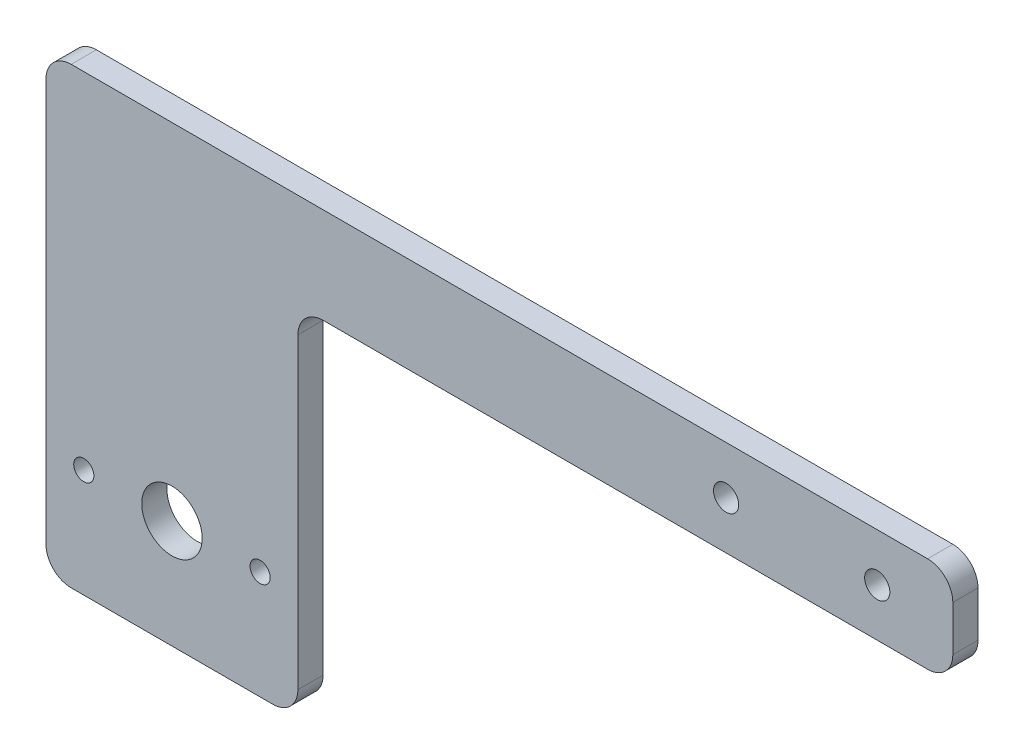
from build123d import *

# Parameters (mm, degrees)
SKETCH1_R           = 2.5
SKETCH1_R_2         = 6
SKETCH1_R_3         = 2
BOSS_EXTRUDE1_DEPTH = 5
FILLET1_R           = 5


with BuildPart() as part:
    # Sketch1 → Boss-Extrude1 (new body)
    with BuildSketch(Plane.XY):
        Polygon((0, 0), (180, 0), (180, -19), (50, -19), (50, -90), (0, -90), align=None)
        with Locations((135, -9.5)):
            Circle(SKETCH1_R, mode=Mode.SUBTRACT)
        with Locations((165, -9.5)):
            Circle(SKETCH1_R, mode=Mode.SUBTRACT)
        with Locations((25, -68.5)):
            Circle(SKETCH1_R_2, mode=Mode.SUBTRACT)
        with Locations((7.5, -68.5)):
            Circle(SKETCH1_R_3, mode=Mode.SUBTRACT)
        with Locations((42.5, -68.5)):
            Circle(SKETCH1_R_3, mode=Mode.SUBTRACT)
    extrude(amount=BOSS_EXTRUDE1_DEPTH)

    # Fillet1
    fillet1_edges = [part.edges().sort_by_distance(p)[0] for p in [
        (0, 0, 2.5),
        (180, 0, 2.5),
        (180, -19, 2.5),
        (50, -19, 2.5),
        (50, -90, 2.5),
        (0, -90, 2.5),
    ]]
    fillet(fillet1_edges, radius=FILLET1_R)


solid = part.part
